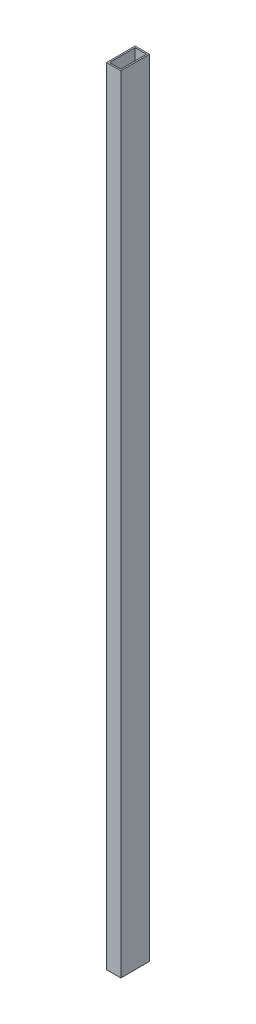
from build123d import *

# Parameters (mm, degrees)
SKETCH_1_W      = 20
SKETCH_1_H      = 40
SKETCH_1_W_2    = 16
SKETCH_1_H_2    = 36
EXTRUDE_1_DEPTH = 1100


with BuildPart() as part:
    # Эскиз1 → Вытянуть-Тонкостенный1 (new body)
    with BuildSketch(Plane(origin=(0, 0, 0), x_dir=(1, 0, 0), z_dir=(0, 1, 0))):
        Rectangle(SKETCH_1_W, SKETCH_1_H)
        Rectangle(SKETCH_1_W_2, SKETCH_1_H_2, mode=Mode.SUBTRACT)
    extrude(amount=EXTRUDE_1_DEPTH)


solid = part.part
